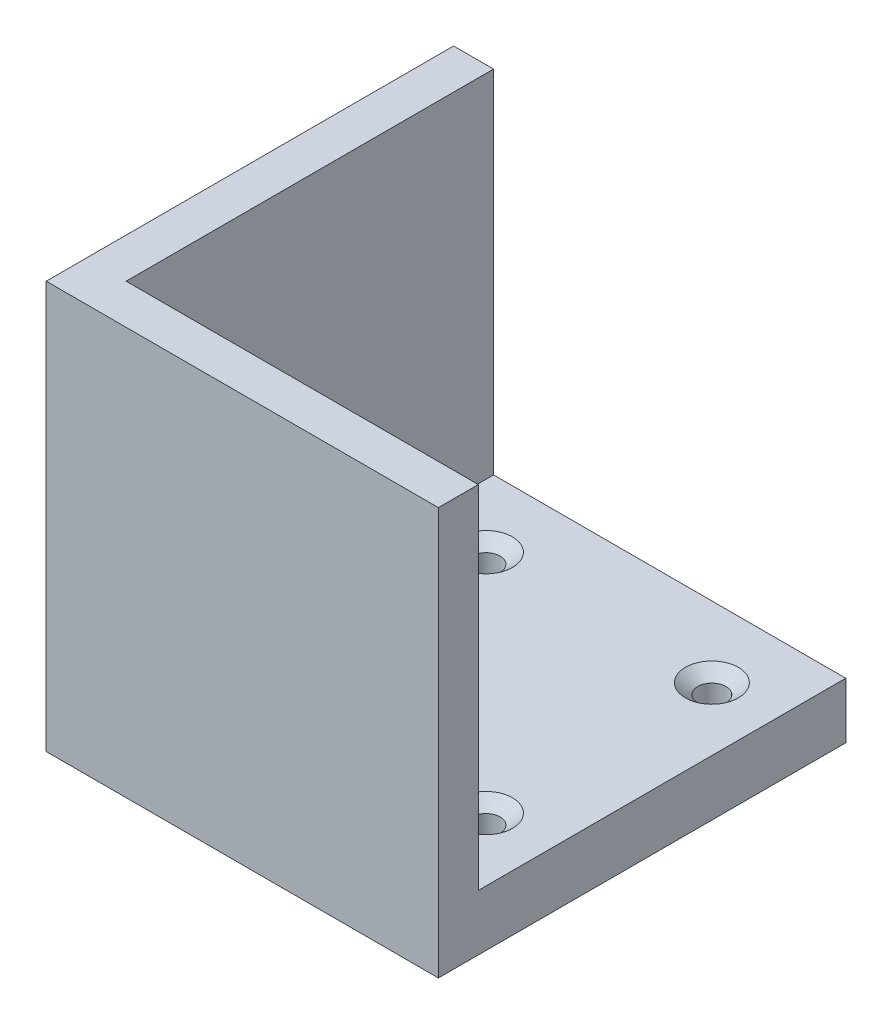
from build123d import *

# Parameters (mm, degrees)
MOTORPROFILE_W                                    = 56
MOTORPROFILE_H                                    = 58.42
BOSS_EXTRUDE2_DEPTH                               = 8.89
BOSS_EXTRUDE3_DEPTH                               = 64.77
CSK_FOR_8_FLAT_HEAD_MACHINE_SCREW_100_D           = 4.4958
CSK_FOR_8_FLAT_HEAD_MACHINE_SCREW_100_CSINK_D     = 8.4328
CSK_FOR_8_FLAT_HEAD_MACHINE_SCREW_100_CSINK_ANGLE = 100


with BuildPart() as part:
    # MotorProfile → Boss-Extrude2 (new body)
    with BuildSketch(Plane(origin=(0, 0, 0), x_dir=(1, 0, 0), z_dir=(0, 1, 0))):
        Rectangle(MOTORPROFILE_W, MOTORPROFILE_H)
    extrude(amount=BOSS_EXTRUDE2_DEPTH)

    # Sketch2 → Boss-Extrude3 (add)
    with BuildSketch(Plane(origin=(0, 0, 0), x_dir=(1, 0, 0), z_dir=(0, 1, 0))):
        Polygon((-34.35, 29.21), (-34.35, -35.56), (28, -35.56), (28, -29.21), (-28, -29.21), (-28, 29.21), align=None)
    extrude(amount=BOSS_EXTRUDE3_DEPTH)

    # CSK for #8 Flat Head Machine Screw (100)2 (through all)
    with Locations(Plane(origin=(0, 8.89, 0), x_dir=(1, 0, 0), z_dir=(0, 1, 0))):
        with Locations((17.960512242, 17.960512242), (17.960512242, -17.960512242), (-17.960512242, -17.960512242), (-17.960512242, 17.960512242)):
            CounterSinkHole(CSK_FOR_8_FLAT_HEAD_MACHINE_SCREW_100_D / 2, CSK_FOR_8_FLAT_HEAD_MACHINE_SCREW_100_CSINK_D / 2, counter_sink_angle=CSK_FOR_8_FLAT_HEAD_MACHINE_SCREW_100_CSINK_ANGLE)


solid = part.part
